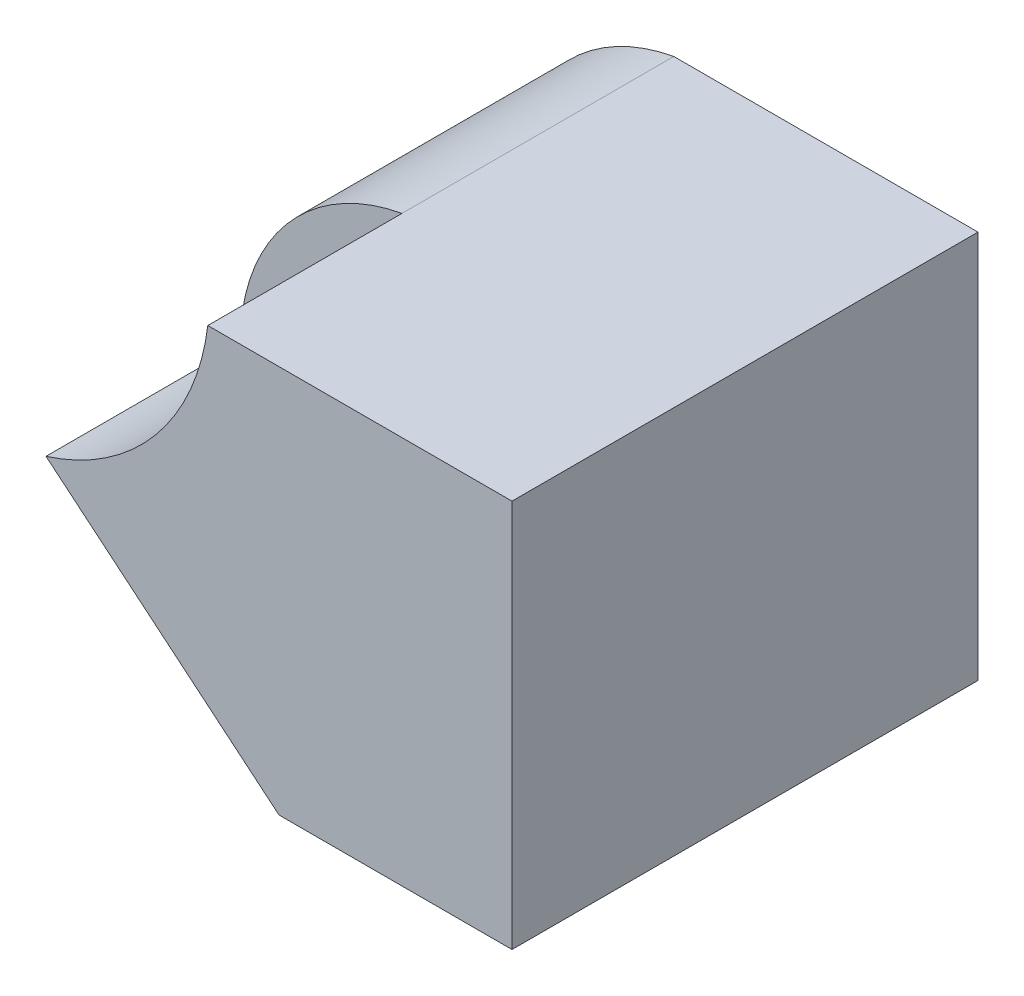
from build123d import *

# Parameters (mm, degrees)
SKETCH1_W           = 6
SKETCH1_H           = 6
BOSS_EXTRUDE1_DEPTH = 5
CUT_EXTRUDE2_DEPTH  = 10
CUT_EXTRUDE3_DEPTH  = 2.5


with BuildPart() as part:
    # Sketch1 → Boss-Extrude1 (new body)
    with BuildSketch(Plane(origin=(0, 0, 0), x_dir=(1, 0, 0), z_dir=(0, 1, 0))):
        Rectangle(SKETCH1_W, SKETCH1_H)
    extrude(amount=BOSS_EXTRUDE1_DEPTH)

    # Sketch5 → Cut-Extrude2 (cut)
    with BuildSketch(Plane.XY.offset(3)):
        with BuildLine():
            Line((-3, 5), (-3, 2.5))
            ThreePointArc((-3, 2.5), (-2.410895752, 4.127135349), (-0.916666667, 5))
            Line((-0.916666667, 5), (-3, 5))
        make_face()
        with BuildLine():
            Line((-3, 0), (-0.916666667, 0))
            ThreePointArc((-0.916666667, 0), (-2.410895752, 0.872864651), (-3, 2.5))
            Line((-3, 2.5), (-3, 0))
        make_face()
    extrude(amount=-CUT_EXTRUDE2_DEPTH, mode=Mode.SUBTRACT)

    # Sketch6 → Cut-Extrude3 (cut)
    with BuildSketch(Plane.XY.offset(3)):
        with BuildLine():
            ThreePointArc((-0.916666667, 5), (-2.410895752, 4.127135349), (-3, 2.5))
            ThreePointArc((-3, 2.5), (-1.589896602, 3.44296939), (-0.916666667, 5))
        make_face()
        with BuildLine():
            Line((0, 0), (-3, 2.5))
            ThreePointArc((-3, 2.5), (-2.410895752, 0.872864651), (-0.916666667, 0))
            Line((-0.916666667, 0), (0, 0))
        make_face()
    extrude(amount=-CUT_EXTRUDE3_DEPTH, mode=Mode.SUBTRACT)


solid = part.part
